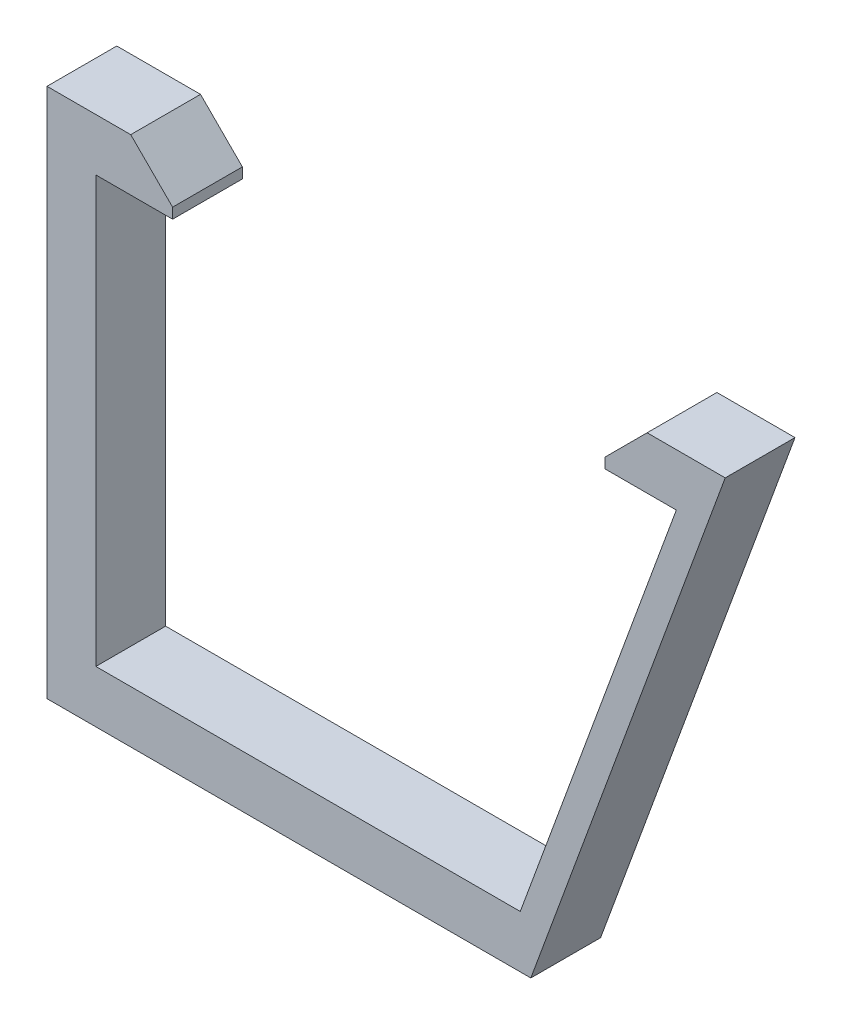
from build123d import *

# Parameters (mm, degrees)
BOSS_EXTRUDE3_DEPTH = 5
CHAMFER3_SIZE       = 3


with BuildPart() as part:
    # Sketch7 → Boss-Extrude3 (new body)
    with BuildSketch(Plane.XY):
        Polygon((-298.426339507, 70), (-284.496051046, 108), (-293.092548077, 108), (-293.092548077, 104.25), (-288.000901442, 104.25), (-299.181790865, 73.75), (-329.592548077, 73.75), (-329.592548077, 104.25), (-324.092548077, 104.25), (-324.092548077, 108), (-333.092548077, 108), (-333.092548077, 70), align=None)
    extrude(amount=BOSS_EXTRUDE3_DEPTH)

    # Chamfer3
    chamfer3_edges = [part.edges().sort_by_distance(p)[0] for p in [
        (-293.092548077, 108, 2.5),
        (-324.092548077, 108, 2.5),
    ]]
    chamfer(chamfer3_edges, length=CHAMFER3_SIZE)


solid = part.part
